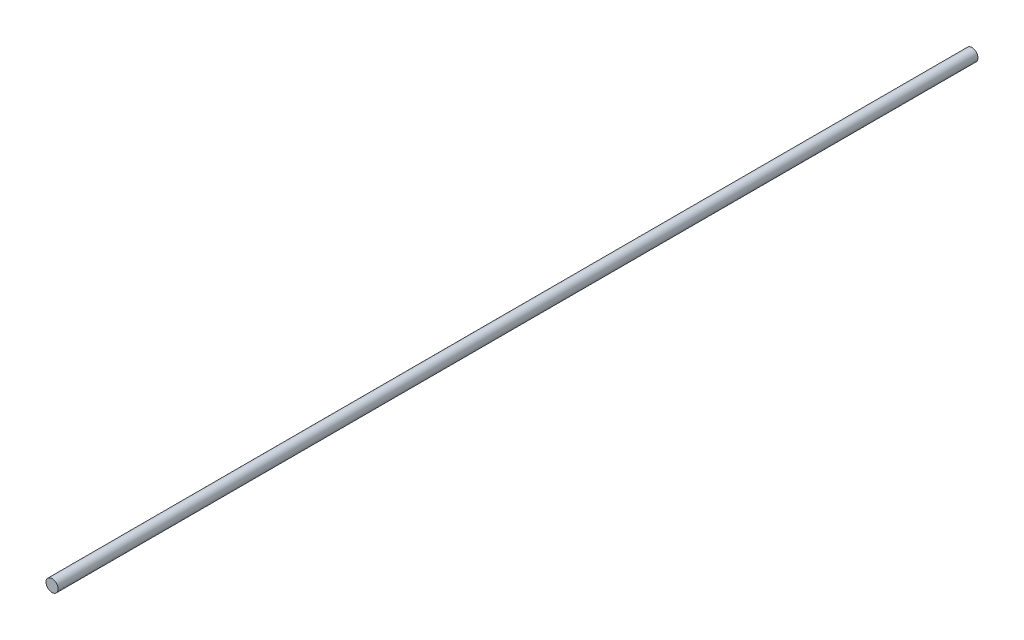
from build123d import *

# Parameters (mm, degrees)
SKETCH1_R           = 4
BOSS_EXTRUDE1_DEPTH = 609.6


with BuildPart() as part:
    # Sketch1 → Boss-Extrude1 (new body)
    with BuildSketch(Plane.XY):
        Circle(SKETCH1_R)
    extrude(amount=BOSS_EXTRUDE1_DEPTH)


solid = part.part
